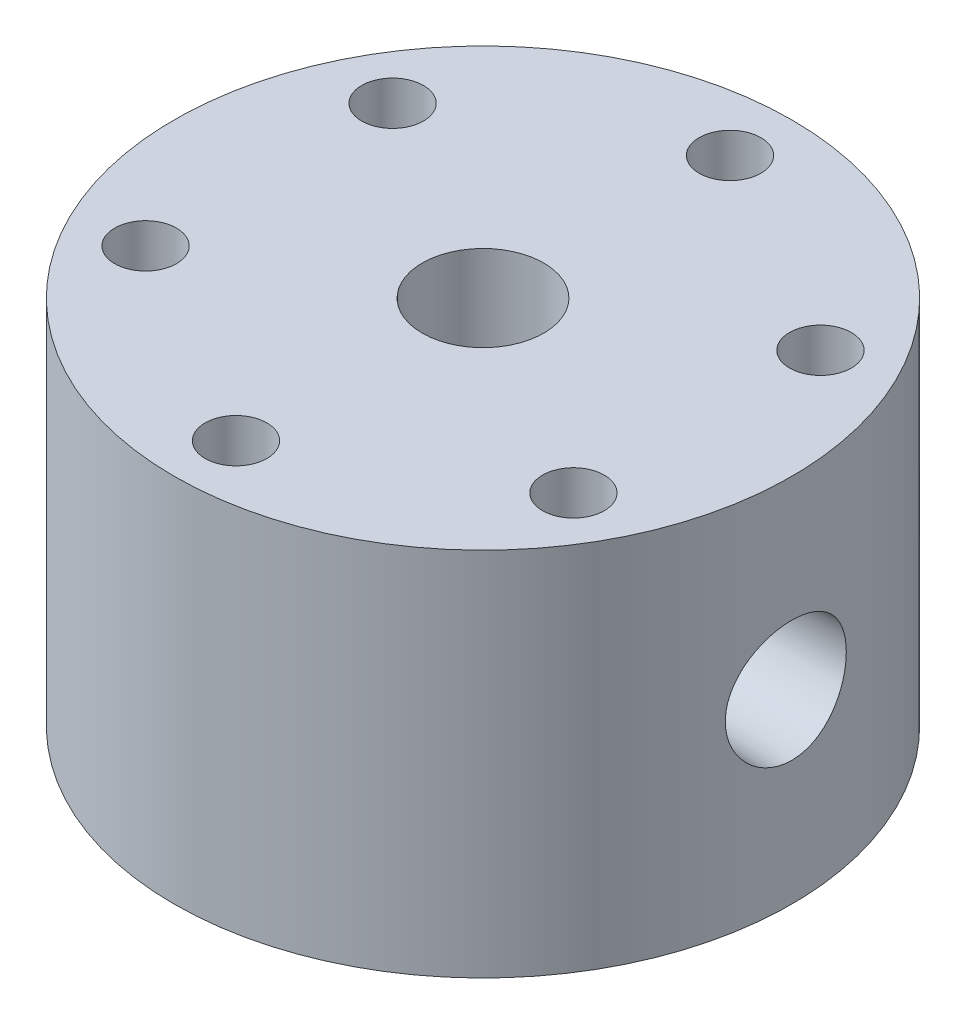
from build123d import *

# Parameters (mm, degrees)
M14X1_5_TAPPED_HOLE1_D              = 12.5
M14X1_5_TAPPED_HOLE1_DEPTH          = 25.4
M14X1_5_TAPPED_HOLE1_TIP            = 3.755378869
F_1_16_0_0625_DIAMETER_HOLE1_D      = 1.5875
F_1_16_0_0625_DIAMETER_HOLE1_DEPTH  = 28.575
F_1_16_0_0625_DIAMETER_HOLE1_TIP    = 0.476933116
F_3_32_0_09375_DIAMETER_HOLE1_D     = 2.38125
F_3_32_0_09375_DIAMETER_HOLE1_DEPTH = 28.702
F_3_32_0_09375_DIAMETER_HOLE1_TIP   = 0.715399675
F_1_4_0_25_DIAMETER_HOLE1_D         = 6.35
CIRPATTERN1_COUNT                   = 6
F_1_32_0_03125_DIAMETER_HOLE1_D     = 0.79375
F_1_32_0_03125_DIAMETER_HOLE1_DEPTH = 28.575
F_1_32_0_03125_DIAMETER_HOLE1_TIP   = 0.238466558


with BuildPart() as part:
    # Sketch1 → Revolve1 (revolve)
    with BuildSketch(Plane.XY):
        Polygon((-3.81, 0), (-8.0645, 0), (-8.0645, 2.032), (-11.1125, 2.032), (-11.1125, 0), (-12.7, 0), (-12.7, -6.35), (-31.75, -6.35), (-31.75, 31.75), (-3.81, 31.75), align=None)
    revolve(axis=Axis((0, 0, 0), (0, 1, 0)))

    # M14x1.5 Tapped Hole1
    with Locations(Plane(origin=(0, 31.75, 0), x_dir=(1, 0, 0), z_dir=(0, 1, 0))):
        with Locations((0, 0)):
            Hole(M14X1_5_TAPPED_HOLE1_D / 2, depth=M14X1_5_TAPPED_HOLE1_DEPTH)
            with Locations((0, 0, -(M14X1_5_TAPPED_HOLE1_DEPTH + M14X1_5_TAPPED_HOLE1_TIP / 2))):  # 118° drill point
                Cone(0, M14X1_5_TAPPED_HOLE1_D / 2, M14X1_5_TAPPED_HOLE1_TIP, mode=Mode.SUBTRACT)

    # Sketch6 → 1/4 NPT Tapped Hole1 (revolve, cut)
    with BuildSketch(Plane(origin=(31.75, 12.7, 0), x_dir=(0, 0, -1), z_dir=(0, 1, 0))):
        Polygon((0, 0), (0, 20.360347279), (5.5626, 17.018), (5.5626, 9.906), (5.943685794, 9.906), (6.2402847, 0), align=None)
    revolve(axis=Axis((38.1, 12.7, 0), (-1, 0, 0)), mode=Mode.SUBTRACT)

    # Sketch8 → 1/4 NPT Tapped Hole2 (revolve, cut)
    with BuildSketch(Plane(origin=(-31.75, 12.7, 0), x_dir=(0, 0, 1), z_dir=(0, 1, 0))):
        Polygon((0, 0), (0, 20.360347279), (5.5626, 17.018), (5.5626, 9.906), (5.943685794, 9.906), (6.2402847, 0), align=None)
    revolve(axis=Axis((-38.1, 12.7, 0), (1, 0, 0)), mode=Mode.SUBTRACT)

    # 1/16 (0.0625) Diameter Hole1
    with Locations(Plane(origin=(31.75, 0, 0), x_dir=(0, 0, -1), z_dir=(1, 0, 0))):
        with Locations((0, 12.7)):
            Hole(F_1_16_0_0625_DIAMETER_HOLE1_D / 2, depth=F_1_16_0_0625_DIAMETER_HOLE1_DEPTH)
            with Locations((0, 0, -(F_1_16_0_0625_DIAMETER_HOLE1_DEPTH + F_1_16_0_0625_DIAMETER_HOLE1_TIP / 2))):  # 118° drill point
                Cone(0, F_1_16_0_0625_DIAMETER_HOLE1_D / 2, F_1_16_0_0625_DIAMETER_HOLE1_TIP, mode=Mode.SUBTRACT)

    # 3/32 (0.09375) Diameter Hole1
    with Locations(Plane.ZY.offset(31.75)):
        with Locations((0, 12.7)):
            Hole(F_3_32_0_09375_DIAMETER_HOLE1_D / 2, depth=F_3_32_0_09375_DIAMETER_HOLE1_DEPTH)
            with Locations((0, 0, -(F_3_32_0_09375_DIAMETER_HOLE1_DEPTH + F_3_32_0_09375_DIAMETER_HOLE1_TIP / 2))):  # 118° drill point
                Cone(0, F_3_32_0_09375_DIAMETER_HOLE1_D / 2, F_3_32_0_09375_DIAMETER_HOLE1_TIP, mode=Mode.SUBTRACT)

    # 1/4 (0.25) Diameter Hole1 (through all)
    with Locations(Plane(origin=(0, 31.75, 0), x_dir=(1, 0, 0), z_dir=(0, 1, 0))):
        with Locations((21.997045256, 12.7)):
            f_1_4_0_25_diameter_hole1 = Hole(F_1_4_0_25_DIAMETER_HOLE1_D / 2)

    # CirPattern1: 1/4 (0.25) Diameter Hole1 ×6 about axis
    cirpattern1_axis = Axis((0, 0, 0), (0, 1, 0))
    for i in range(1, CIRPATTERN1_COUNT):
        add(f_1_4_0_25_diameter_hole1.rotate(cirpattern1_axis, i * 360 / CIRPATTERN1_COUNT), mode=Mode.SUBTRACT)

    # Sketch18 → 1/4 NPT Tapped Hole3 (revolve, cut)
    with BuildSketch(Plane(origin=(15.875, 12.7, -27.49630657), x_dir=(-0.866025404, 0, -0.5), z_dir=(0, 1, 0))):
        Polygon((0, 0), (0, 19.852347279), (5.5626, 16.51), (5.5626, 12.7), (6.557983593, 12.7), (6.9382386, 0), align=None)
    revolve(axis=Axis((19.05, 12.7, -32.995567884), (-0.5, 0, 0.866025404)), mode=Mode.SUBTRACT)

    # 1/32 (0.03125) Diameter Hole1
    with Locations(Plane(origin=(15.875, 0, -27.49630657), x_dir=(0, -1, 0), z_dir=(0.5, 0, -0.866025404))):
        with Locations((-12.7, 0)):
            Hole(F_1_32_0_03125_DIAMETER_HOLE1_D / 2, depth=F_1_32_0_03125_DIAMETER_HOLE1_DEPTH)
            with Locations((0, 0, -(F_1_32_0_03125_DIAMETER_HOLE1_DEPTH + F_1_32_0_03125_DIAMETER_HOLE1_TIP / 2))):  # 118° drill point
                Cone(0, F_1_32_0_03125_DIAMETER_HOLE1_D / 2, F_1_32_0_03125_DIAMETER_HOLE1_TIP, mode=Mode.SUBTRACT)


solid = part.part
